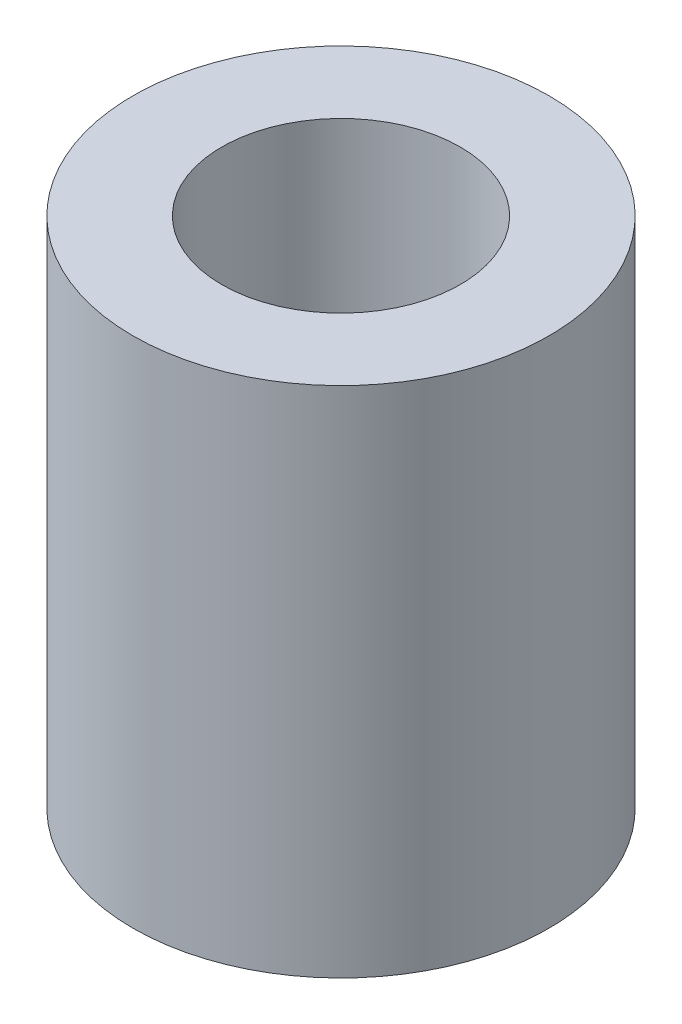
from build123d import *

# Parameters (mm, degrees)
SKETCH1_R           = 4.7625
SKETCH1_R_2         = 2.7305
BOSS_EXTRUDE1_DEPTH = 11.7475


with BuildPart() as part:
    # Sketch1 → Boss-Extrude1 (new body)
    with BuildSketch(Plane(origin=(0, 0, 0), x_dir=(1, 0, 0), z_dir=(0, 1, 0))):
        Circle(SKETCH1_R)
        Circle(SKETCH1_R_2, mode=Mode.SUBTRACT)
    extrude(amount=BOSS_EXTRUDE1_DEPTH)


solid = part.part
